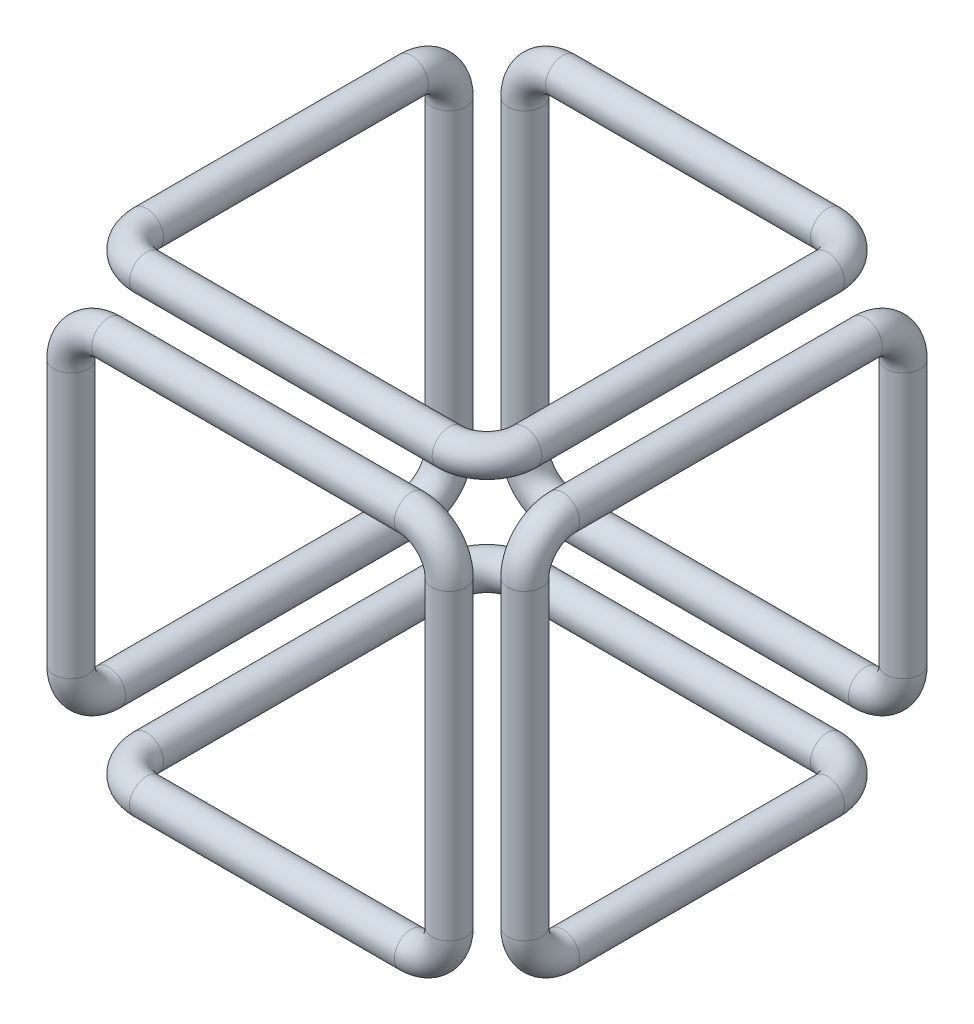
from build123d import *

# Parameters (mm, degrees)
SKETCH_1_R = 4.5


with BuildPart() as part:
    # ｽｲｰﾌﾟ1: sweep along a curve in space
    with BuildLine() as sweep_1_path:
        Line((90, 0, 0), (10, 0, 0))
        ThreePointArc((0, 0, 10), (2.928932188, 0, 2.928932188), (10, 0, 0))
        Line((0, 0, 90), (0, 0, 10))
        ThreePointArc((10, 0, 100), (2.928932188, 0, 97.071067812), (0, 0, 90))
        Line((80, 0, 100), (10, 0, 100))
        ThreePointArc((90, 10, 100), (87.071067812, 2.928932188, 100), (80, 0, 100))
        Line((90, 90, 100), (90, 10, 100))
        ThreePointArc((80, 100, 100), (87.071067812, 97.071067812, 100), (90, 90, 100))
        Line((0, 100, 100), (80, 100, 100))
        ThreePointArc((-10, 90, 100), (-7.071067812, 97.071067812, 100), (0, 100, 100))
        Line((-10, 20, 100), (-10, 90, 100))
        ThreePointArc((-10, 10, 90), (-10, 12.928932188, 97.071067812), (-10, 20, 100))
        Line((-10, 10, 10), (-10, 10, 90))
        ThreePointArc((-10, 20, 0), (-10, 12.928932188, 2.928932188), (-10, 10, 10))
        Line((-10, 100, 0), (-10, 20, 0))
        ThreePointArc((-10, 110, 10), (-10, 107.071067812, 2.928932188), (-10, 100, 0))
        Line((-10, 110, 80), (-10, 110, 10))
        ThreePointArc((0, 110, 90), (-7.071067812, 110, 87.071067812), (-10, 110, 80))
        Line((80, 110, 90), (0, 110, 90))
        ThreePointArc((90, 110, 80), (87.071067812, 110, 87.071067812), (80, 110, 90))
        Line((90, 110, 0), (90, 110, 80))
        ThreePointArc((80, 110, -10), (87.071067812, 110, -7.071067812), (90, 110, 0))
        Line((10, 110, -10), (80, 110, -10))
        ThreePointArc((0, 100, -10), (2.928932188, 107.071067812, -10), (10, 110, -10))
        Line((0, 20, -10), (0, 100, -10))
        ThreePointArc((10, 10, -10), (2.928932188, 12.928932188, -10), (0, 20, -10))
        Line((90, 10, -10), (10, 10, -10))
        ThreePointArc((100, 20, -10), (97.071067812, 12.928932188, -10), (90, 10, -10))
        Line((100, 90, -10), (100, 20, -10))
        ThreePointArc((100, 100, 0), (100, 97.071067812, -7.071067812), (100, 90, -10))
        Line((100, 100, 80), (100, 100, 0))
        ThreePointArc((100, 90, 90), (100, 97.071067812, 87.071067812), (100, 100, 80))
        Line((100, 10, 90), (100, 90, 90))
        ThreePointArc((100, 0, 80), (100, 2.928932188, 87.071067812), (100, 10, 90))
        Line((100, 0, 10), (100, 0, 80))
        ThreePointArc((100, 0, 10), (97.071067812, 0, 2.928932188), (90, 0, 0))
    # ｽｹｯﾁ1 → ｽｲｰﾌﾟ1 (sweep)
    with BuildSketch(Plane.XY.offset(10)):
        with Locations((100, 0)):
            Circle(SKETCH_1_R)
    sweep(path=sweep_1_path.line)


solid = part.part
